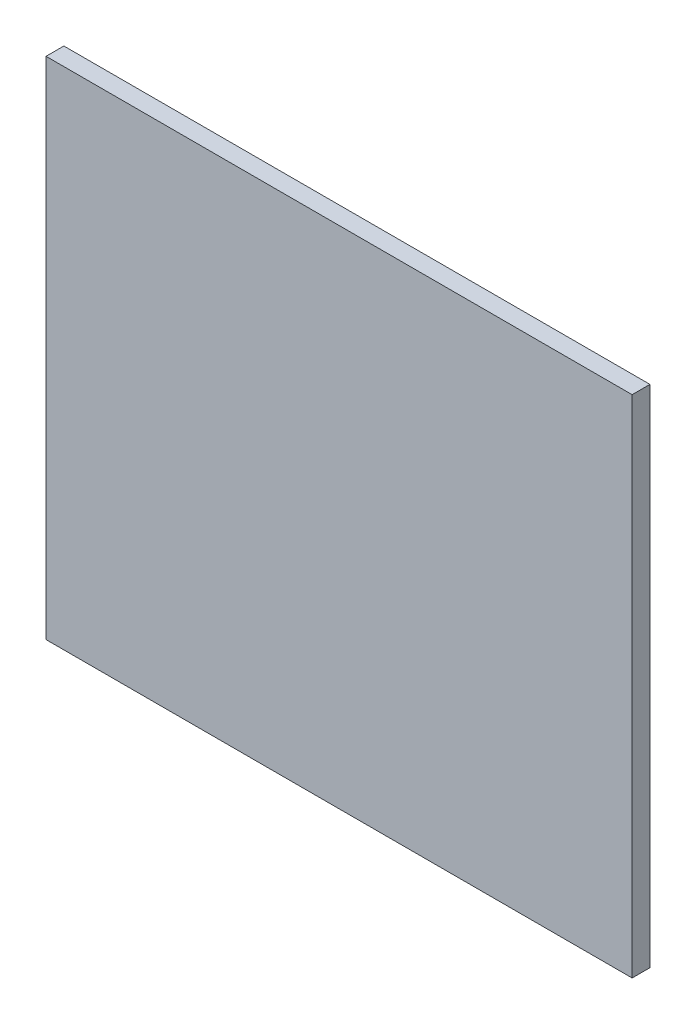
from build123d import *

# Parameters (mm, degrees)
ESBO_O1_W                = 104.4125
ESBO_O1_H                = 90
RESSALTO_EXTRUS_O1_DEPTH = 3.175


with BuildPart() as part:
    # Esboço1 → Ressalto-extrusão1 (new body)
    with BuildSketch(Plane.XY):
        Rectangle(ESBO_O1_W, ESBO_O1_H)
    extrude(amount=RESSALTO_EXTRUS_O1_DEPTH)


solid = part.part
